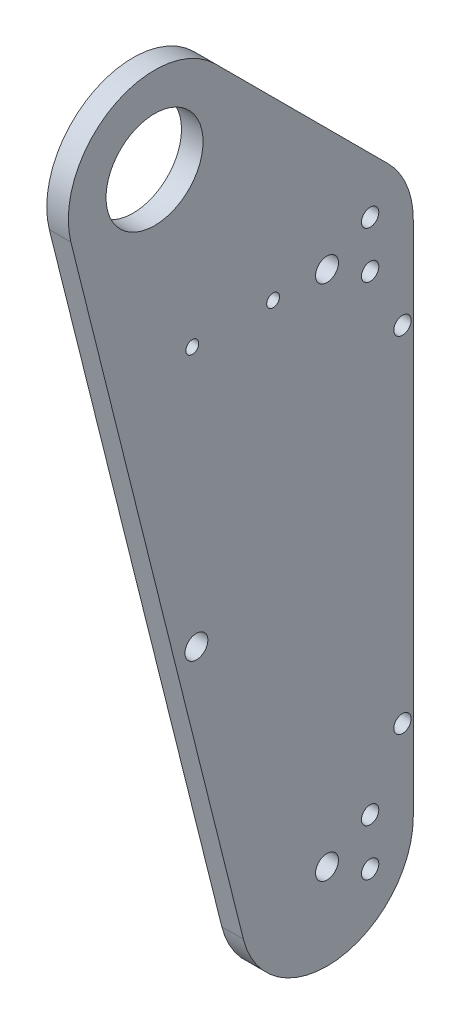
from build123d import *

# Parameters (mm, degrees)
BOSS_EXTRUDE1_DEPTH     = 6.35
F_1_1_DIAMETER_HOLE1_D  = 28.575
F_1_4_CLEARANCE_HOLE1_D = 6.7564
F_1_4_20_TAPPED_HOLE1_D = 5.1054
F_10_24_TAPPED_HOLE1_D  = 3.7973
F_10_CLEARANCE_HOLE1_D  = 5.1054


with BuildPart() as part:
    # Sketch2 → Boss-Extrude1 (new body)
    with BuildSketch(Plane(origin=(0, 0, 0), x_dir=(0, 0, -1), z_dir=(1, 0, 0))):
        with BuildLine():
            Line((68.760512242, -32.839487758), (17.960512242, 17.960512242))
            ThreePointArc((17.960512242, 17.960512242), (-12.514549901, 22.103077632), (-24.641619504, -6.160404876))
            Line((-24.641619504, -6.160404876), (26.158380496, -209.360404876))
            ThreePointArc((26.158380496, -209.360404876), (53.903454898, -228.40969194), (76.2, -203.2))
            Line((76.2, -203.2), (76.2, -50.8))
            ThreePointArc((76.2, -50.8), (74.266540126, -41.079840818), (68.760512242, -32.839487758))
        make_face()
    extrude(amount=BOSS_EXTRUDE1_DEPTH)

    # 1 (1) Diameter Hole1 (through all)
    with Locations(Plane(origin=(6.35, 0, 0), x_dir=(0, 0, -1), z_dir=(1, 0, 0))):
        with Locations((0, 0)):
            Hole(F_1_1_DIAMETER_HOLE1_D / 2)

    # 1/4 Clearance Hole1 (through all)
    with Locations(Plane(origin=(6.35, 0, 0), x_dir=(0, 0, -1), z_dir=(1, 0, 0))):
        with Locations((50.8, -50.8), (50.8, -203.2), (12.320809752, -127.828401175)):
            Hole(F_1_4_CLEARANCE_HOLE1_D / 2)

    # 1/4-20 Tapped Hole1 (through all)
    with Locations(Plane.ZY):
        with Locations((-63.5, -57.7088), (-63.5, -43.8912), (-63.5, -196.2912), (-63.5, -210.1088)):
            Hole(F_1_4_20_TAPPED_HOLE1_D / 2)

    # #10-24 Tapped Hole1 (through all)
    with Locations(Plane.ZY):
        with Locations((-34.925, -50.8), (-11.1125, -50.8)):
            Hole(F_10_24_TAPPED_HOLE1_D / 2)

    # #10 Clearance Hole1 (through all)
    with Locations(Plane.ZY):
        with Locations((-73.025, -76.2), (-73.025, -177.8)):
            Hole(F_10_CLEARANCE_HOLE1_D / 2)


solid = part.part
